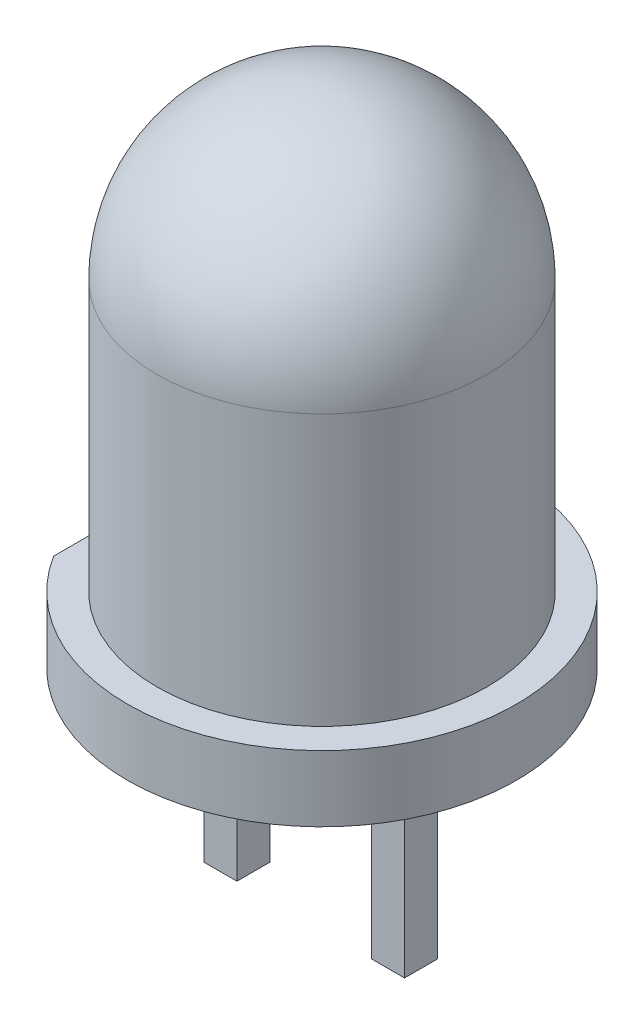
from build123d import *

# Parameters (mm, degrees)
CROQUIS3_W              = 0.5
CROQUIS3_H              = 0.5
SALIENTE_EXTRUIR3_DEPTH = 25.4
CROQUIS4_W              = 0.912534335
CROQUIS4_H              = 5.586103973
CORTAR_EXTRUIR1_DEPTH   = 25.4
CORTAR_EXTRUIR2_REACH   = 5.219
CROQUIS5_W              = 0.5
CROQUIS5_H              = 1
SKETCH1_W               = 3.04
SKETCH1_H               = 22.225
CUT_EXTRUDE1_DEPTH      = 4.181185999


with BuildPart() as part:
    # Croquis2 → Revolución1 (revolve)
    with BuildSketch(Plane(origin=(0, 0, 0), x_dir=(0, 0, -1), z_dir=(1, 0, 0))):
        with BuildLine():
            Line((0, -919.589259582), (2.95, -919.589259582))
            Line((2.95, -919.589259582), (2.95, -918.589259582))
            Line((2.95, -918.589259582), (2.5, -918.589259582))
            Line((2.5, -918.589259582), (2.5, -914.489259582))
            ThreePointArc((2.5, -914.489259582), (1.767766953, -912.721492629), (0, -911.989259582))
            Line((0, -911.989259582), (0, -919.589259582))
        make_face()
    revolve(axis=Axis((0, -1491.471633976, 0), (0, 1, 0)))

    # Croquis3 → Saliente-Extruir3 (add)
    with BuildSketch(Plane.XZ.offset(919.589259582)):
        with Locations((1.27, 0.018814001)):
            Rectangle(CROQUIS3_W, CROQUIS3_H)
        with Locations((-1.27, 0.018814001)):
            Rectangle(CROQUIS3_W, CROQUIS3_H)
    extrude(amount=SALIENTE_EXTRUIR3_DEPTH)

    # Croquis4 → Cortar-Extruir1 (cut)
    with BuildSketch(Plane(origin=(0, -918.589259582, 0), x_dir=(1, 0, 0), z_dir=(0, 1, 0))):
        with Locations((-2.956267168, 0.283432647)):
            Rectangle(CROQUIS4_W, CROQUIS4_H)
    extrude(amount=-CORTAR_EXTRUIR1_DEPTH, mode=Mode.SUBTRACT)

    # Croquis5 → Cortar-Extruir2 (cut, up to next)
    with BuildSketch(Plane.XY.offset(0.268814001), mode=Mode.PRIVATE) as cortar_extruir2_sk1:
        with Locations((-1.27, -944.489259582)):
            Rectangle(CROQUIS5_W, CROQUIS5_H)
    cortar_extruir2_tool1 = extrude(cortar_extruir2_sk1.sketch, amount=-CORTAR_EXTRUIR2_REACH, mode=Mode.PRIVATE) & part.part
    add(cortar_extruir2_tool1.solids().sort_by_distance((-1.27, -944.48926, 0.268814))[0], mode=Mode.SUBTRACT)

    # Sketch1 → Cut-Extrude1 (cut, through all)
    with BuildSketch(Plane(origin=(0, 0, -0.231185999), x_dir=(-1, 0, 0), z_dir=(0, 0, -1))):
        with Locations((0, -933.876759582)):
            Rectangle(SKETCH1_W, SKETCH1_H)
    extrude(amount=-CUT_EXTRUDE1_DEPTH, mode=Mode.SUBTRACT)


solid = part.part
